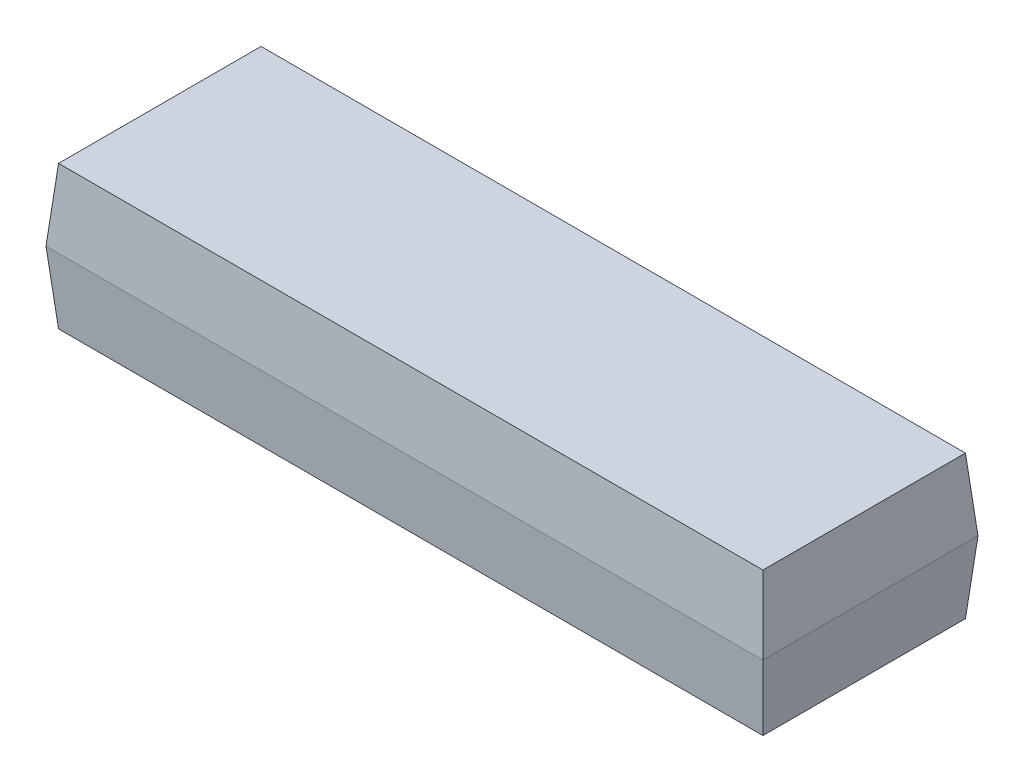
from build123d import *

# Parameters (mm, degrees)
SKETCH1_W                     = 10
SKETCH1_H                     = 3
BOSS_EXTRUDE1_DEPTH           = 1
BOSS_EXTRUDE1_TAPER           = 5
BOSS_EXTRUDE1_OTHER_WAY_DEPTH = 1
BOSS_EXTRUDE1_OTHER_WAY_TAPER = 5


with BuildPart() as part:
    # Sketch1 → Boss-Extrude1 (new body)
    with BuildSketch(Plane(origin=(0, 0, 0), x_dir=(1, 0, 0), z_dir=(0, 1, 0))):
        Rectangle(SKETCH1_W, SKETCH1_H)
    extrude(amount=BOSS_EXTRUDE1_DEPTH, taper=BOSS_EXTRUDE1_TAPER)

    # Sketch1 → Boss-Extrude1 other way (add)
    with BuildSketch(Plane(origin=(0, 0, 0), x_dir=(1, 0, 0), z_dir=(0, 1, 0))):
        Rectangle(SKETCH1_W, SKETCH1_H)
    extrude(amount=-BOSS_EXTRUDE1_OTHER_WAY_DEPTH, taper=BOSS_EXTRUDE1_OTHER_WAY_TAPER)


solid = part.part
